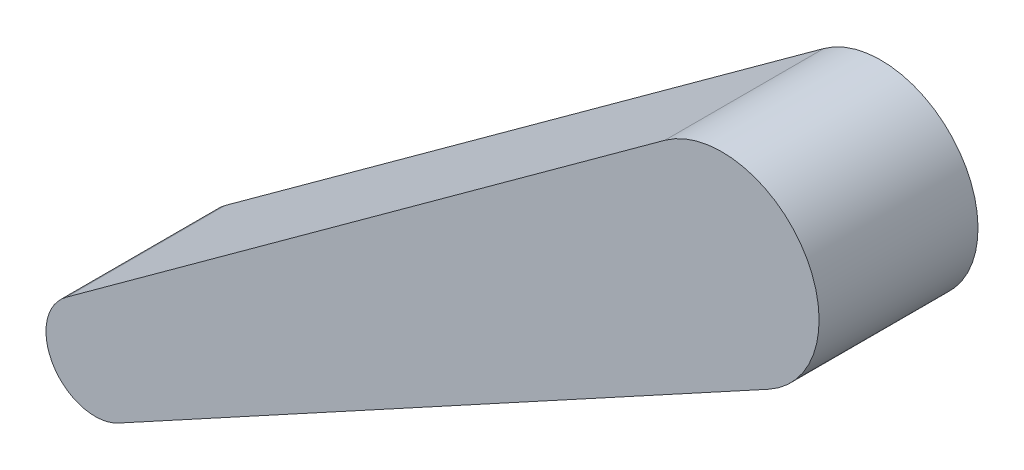
from build123d import *

# Parameters (mm, degrees)
BOSS_EXTRUDE1_DEPTH = 114.3


with BuildPart() as part:
    # Sketch1 → Boss-Extrude1 (new body)
    with BuildSketch(Plane.XY):
        with BuildLine():
            Line((-1548.664863268, 532.802052348), (-1979.189187563, 219.79873247))
            ThreePointArc((-1979.189187563, 219.79873247), (-1988.268924531, 172.373713189), (-1941.531483547, 160.241702328))
            Line((-1941.531483547, 160.241702328), (-1474.162211439, 414.973395591))
            ThreePointArc((-1474.162211439, 414.973395591), (-1448.551842086, 513.634956305), (-1548.664863268, 532.802052348))
        make_face()
    extrude(amount=-BOSS_EXTRUDE1_DEPTH)


solid = part.part
